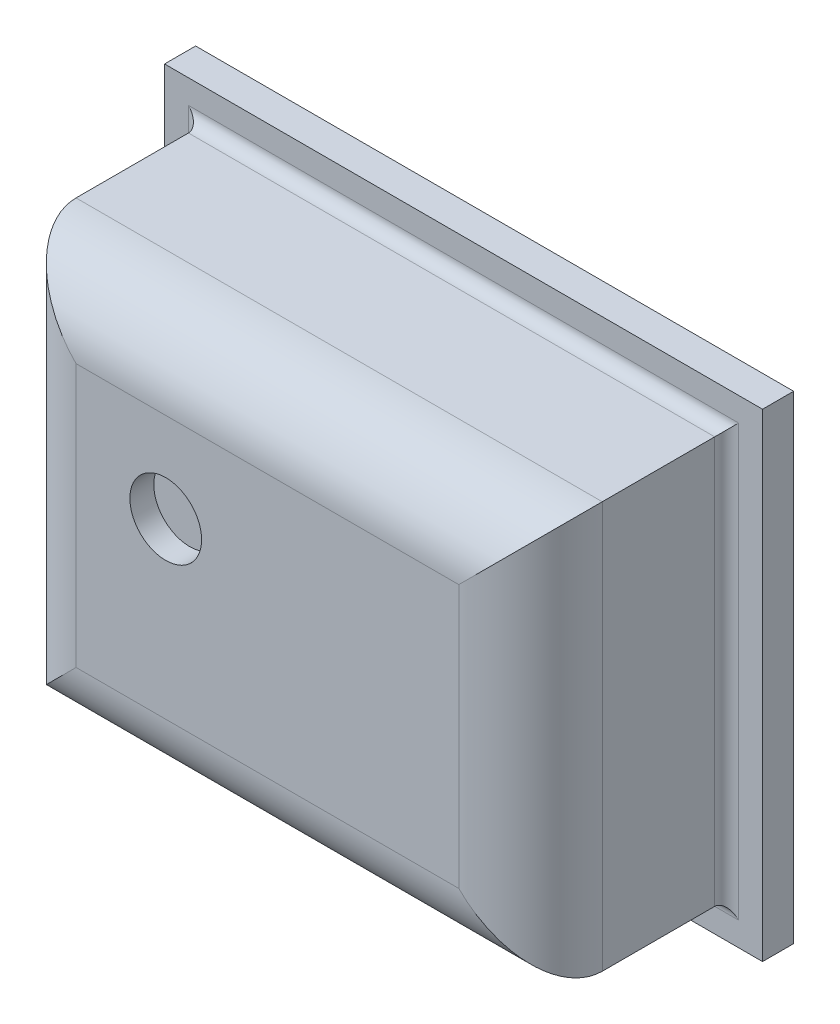
from build123d import *

# Parameters (mm, degrees)
ESQUISSE1_W             = 2.5
ESQUISSE1_H             = 2
BOSS_EXTRU_1_DEPTH      = 0.13
ESQUISSE2_W             = 2.2
ESQUISSE2_H             = 1.7
BOSS_EXTRU_2_DEPTH      = 0.82
CONG_1_R                = 0.3
ESQUISSE3_R             = 0.15
ENL_V_MAT_EXTRU_1_DEPTH = 0.1
CONG_2_R                = 0.05


with BuildPart() as part:
    # Esquisse1 → Boss.-Extru.1 (new body)
    with BuildSketch(Plane.XY):
        Rectangle(ESQUISSE1_W, ESQUISSE1_H)
    extrude(amount=BOSS_EXTRU_1_DEPTH)

    # Esquisse2 → Boss.-Extru.2 (add)
    with BuildSketch(Plane.XY.offset(0.13)):
        Rectangle(ESQUISSE2_W, ESQUISSE2_H)
    extrude(amount=BOSS_EXTRU_2_DEPTH)

    # Congé1
    cong_1_edges = [part.edges().sort_by_distance(p)[0] for p in [
        (1.1, 0, 0.95),
        (0, 0.85, 0.95),
        (-1.1, 0, 0.95),
        (0, -0.85, 0.95),
    ]]
    fillet(cong_1_edges, radius=CONG_1_R)

    # Esquisse3 → Enlèv. mat.-Extru.1 (cut)
    with BuildSketch(Plane.XY.offset(0.95)):
        with Locations((-0.425, 0.175)):
            Circle(ESQUISSE3_R)
    extrude(amount=-ENL_V_MAT_EXTRU_1_DEPTH, mode=Mode.SUBTRACT)

    # Congé2
    cong_2_edges = [part.edges().sort_by_distance(p)[0] for p in [
        (1.1, 0, 0.13),
        (0, 0.85, 0.13),
        (-1.1, 0, 0.13),
        (0, -0.85, 0.13),
    ]]
    fillet(cong_2_edges, radius=CONG_2_R)


solid = part.part
